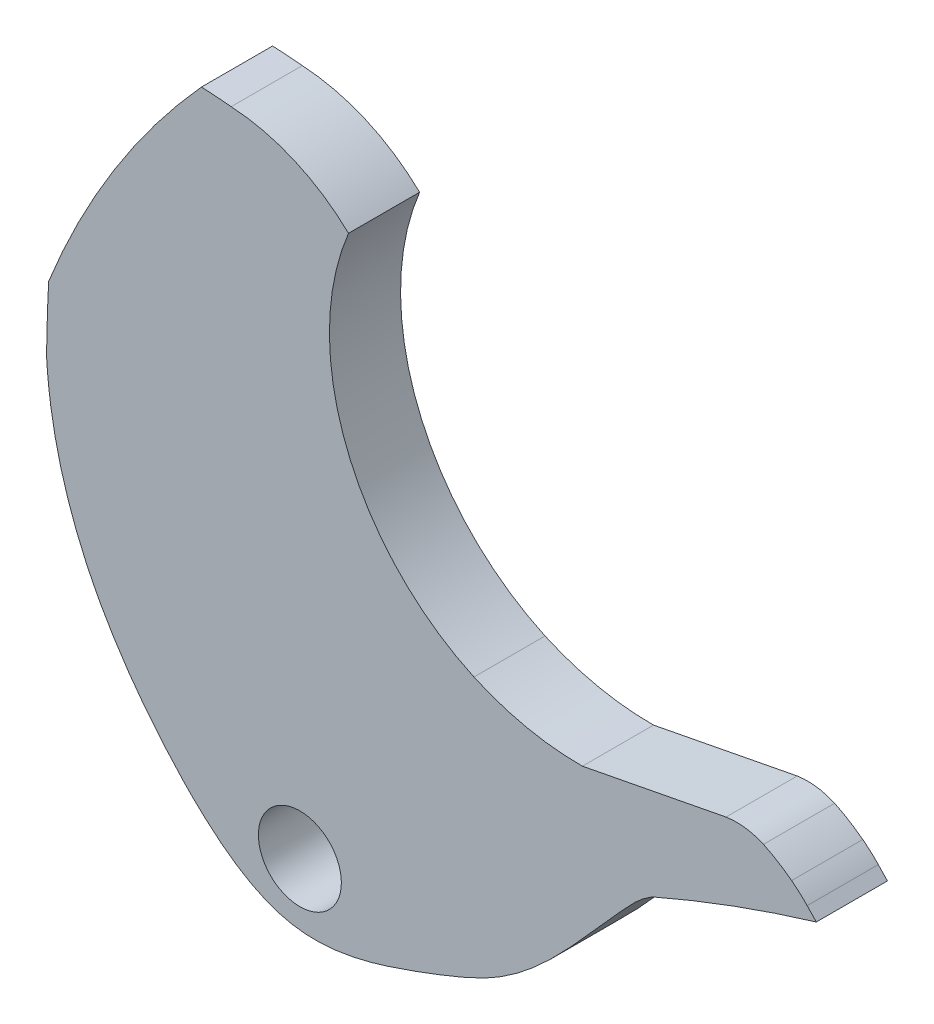
from build123d import *

# Parameters (mm, degrees)
SKETCH1_R           = 1.75
BOSS_EXTRUDE1_DEPTH = 3


with BuildPart() as part:
    # Sketch1 → Boss-Extrude1 (new body)
    with BuildSketch(Plane.XY):
        with BuildLine():
            Line((19.930411003, 2.905988798), (13.87145238, 1.735459786))
            ThreePointArc((13.87145238, 1.735459786), (11.531557717, 1.972597442), (9.296030987, 2.703187301))
            ThreePointArc((9.296030987, 2.703187301), (3.919484189, 8.419131518), (4.006841218, 16.265891519))
            ThreePointArc((4.006841218, 16.265891519), (1.723665713, 17.781070836), (-0.941946899, 18.416026075))
            ThreePointArc((-0.941946899, 18.416026075), (-1.568863415, 18.470126635), (-2.197160171, 18.50468636))
            ThreePointArc((-2.197160171, 18.50468636), (-5.87970066, 13.635417111), (-8.639038917, 8.189598545))
            ThreePointArc((-8.639038917, 8.189598545), (-8.697179287, 6.801867653), (-8.727525387, 5.413250916))
            ThreePointArc((-8.727525387, 5.413250916), (-8.707936379, 5.106364202), (-8.683372389, 4.799835582))
            add(Edge.make_bspline(
                [(-8.683372389, 4.799835582), (-8.588074591, 3.721163805), (-8.402294299, 2.674479561), (-7.859371187, 0.648508115), (-7.502052979, -0.331606117), (-7.064007696, -1.28129998)],
                knots=[0, 0, 0, 0, 0.5, 0.5, 1, 1, 1, 1], degree=3))
            add(Edge.make_bspline(
                [(-7.064007696, -1.28129998), (-6.575170871, -2.34111126), (-5.98506043, -3.361216675), (-4.957629948, -4.84262589), (-4.59187789, -5.329143335), (-3.817976232, -6.281801183), (-3.40882724, -6.74810305), (-2.97381792, -7.203826342)],
                knots=[0, 0, 0, 0, 0.5, 0.5, 0.75, 0.75, 1, 1, 1, 1], degree=3))
            add(Edge.make_bspline(
                [(-2.97381792, -7.203826342), (-2.306446509, -7.902976179), (-1.590279206, -8.56570689), (-0.445412997, -9.35234524), (-0.053513063, -9.579507747), (0.556953087, -9.853650755), (0.764136141, -9.933887283), (1.181773294, -10.067725648), (1.391009263, -10.121047129), (1.602766598, -10.159905725)],
                knots=[0, 0, 0, 0, 0.5, 0.5, 0.75, 0.75, 0.875, 0.875, 1, 1, 1, 1], degree=3))
            add(Edge.make_bspline(
                [(1.602766598, -10.159905725), (2.019871783, -10.236446742), (2.459018956, -10.260016432), (3.337272754, -10.220368292), (3.779944348, -10.157384511), (4.227454337, -10.064224837)],
                knots=[0, 0, 0, 0, 0.5, 0.5, 1, 1, 1, 1], degree=3))
            add(Edge.make_bspline(
                [(4.227454337, -10.064224837), (5.089770185, -9.88471362), (5.962802505, -9.592227299), (6.811456082, -9.284683988)],
                knots=[0, 0, 0, 0, 1, 1, 1, 1], degree=3))
            add(Edge.make_bspline(
                [(6.811456082, -9.284683988), (7.056520313, -9.195875236), (7.297794582, -9.106311657), (7.776758126, -8.924041304), (8.015576329, -8.831105295), (8.722360856, -8.547506225), (9.179802119, -8.35044286), (9.620286504, -8.127847225)],
                knots=[0, 0, 0, 0, 0.25, 0.25, 0.5, 0.5, 1, 1, 1, 1], degree=3))
            add(Edge.make_bspline(
                [(9.620286504, -8.127847225), (9.800382572, -8.036836964), (9.977339671, -7.94180455), (10.322866167, -7.742648629), (10.490967018, -7.638558401), (10.990123709, -7.307373872), (11.312673774, -7.064183232), (12.24261019, -6.291133214), (12.820931233, -5.712035881), (13.94631914, -4.501489979), (14.49233771, -3.8697351), (15.184900578, -3.09577571), (15.323634143, -2.942251733), (15.602122385, -2.637726794), (15.743780167, -2.483440537), (16.029801415, -2.186068127), (16.169367003, -2.0474533), (16.479304052, -1.785805781), (16.652919268, -1.664467301), (16.828175246, -1.561356406)],
                knots=[0, 0, 0, 0, 0.0625, 0.0625, 0.125, 0.125, 0.25, 0.25, 0.5, 0.5, 0.75, 0.75, 0.8125, 0.8125, 0.875, 0.875, 0.9375, 0.9375, 1, 1, 1, 1], degree=3))
            ThreePointArc((16.828175246, -1.561356406), (20.244272985, -0.189669108), (23.736412446, 0.974895959))
            Line((23.736412446, 0.974895959), (23.351331305, 1.380731944))
            ThreePointArc((23.351331305, 1.380731944), (23.035702836, 1.68776393), (22.696524646, 1.968563017))
            ThreePointArc((22.696524646, 1.968563017), (22.121114049, 2.363611886), (21.509254361, 2.699452157))
            ThreePointArc((21.509254361, 2.699452157), (20.73478902, 2.91705232), (19.930411003, 2.905988798))
        make_face()
        with Locations((1.955579729, -7.60507725)):
            Circle(SKETCH1_R, mode=Mode.SUBTRACT)
    extrude(amount=BOSS_EXTRUDE1_DEPTH)


solid = part.part
